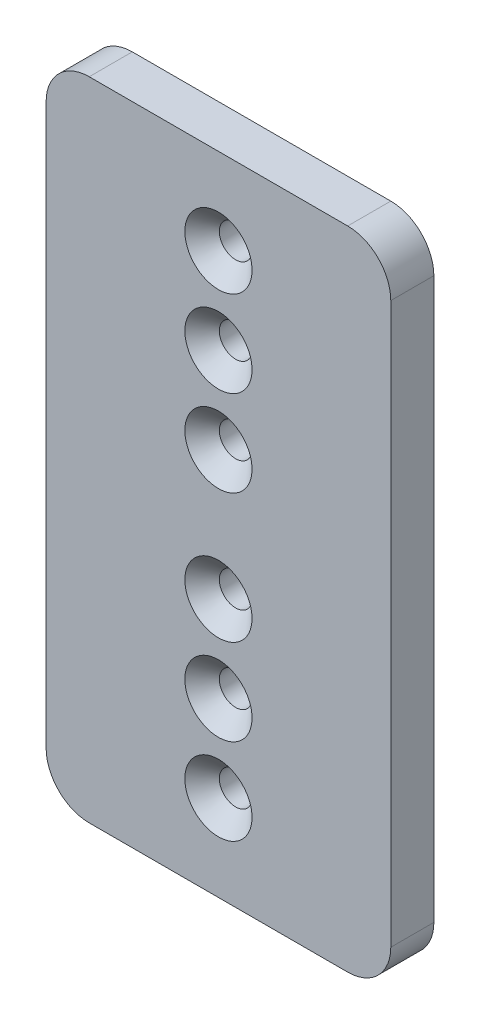
from build123d import *

# Parameters (mm, degrees)
SKETCH1_W           = 50.8
SKETCH1_H           = 95.25
SKETCH1_R           = 2.413
BOSS_EXTRUDE1_DEPTH = 6.35
FILLET1_R           = 6.35
CHAMFER1_SIZE       = 2.54


with BuildPart() as part:
    # Sketch1 → Boss-Extrude1 (new body)
    with BuildSketch(Plane.XY):
        with Locations((25.4, 47.625)):
            Rectangle(SKETCH1_W, SKETCH1_H)
        with Locations((25.4, 69.85)):
            Circle(SKETCH1_R, mode=Mode.SUBTRACT)
        with Locations((25.4, 25.4)):
            Circle(SKETCH1_R, mode=Mode.SUBTRACT)
        with Locations((25.4, 57.15)):
            Circle(SKETCH1_R, mode=Mode.SUBTRACT)
        with Locations((25.4, 12.7)):
            Circle(SKETCH1_R, mode=Mode.SUBTRACT)
        with Locations((25.4, 38.1)):
            Circle(SKETCH1_R, mode=Mode.SUBTRACT)
        with Locations((25.4, 82.55)):
            Circle(SKETCH1_R, mode=Mode.SUBTRACT)
    extrude(amount=BOSS_EXTRUDE1_DEPTH)

    # Fillet1
    fillet1_edges = [part.edges().sort_by_distance(p)[0] for p in [
        (0, 95.25, 3.175),
        (50.8, 95.25, 3.175),
        (50.8, 0, 3.175),
        (0, 0, 3.175),
    ]]
    fillet(fillet1_edges, radius=FILLET1_R)

    # Chamfer1
    chamfer1_edges = [part.edges().sort_by_distance(p)[0] for p in [
        (22.987, 69.85, 6.35),
        (22.987, 25.4, 6.35),
        (22.987, 57.15, 6.35),
        (22.987, 12.7, 6.35),
        (22.987, 38.1, 6.35),
        (22.987, 82.55, 6.35),
    ]]
    chamfer(chamfer1_edges, length=CHAMFER1_SIZE)


solid = part.part
